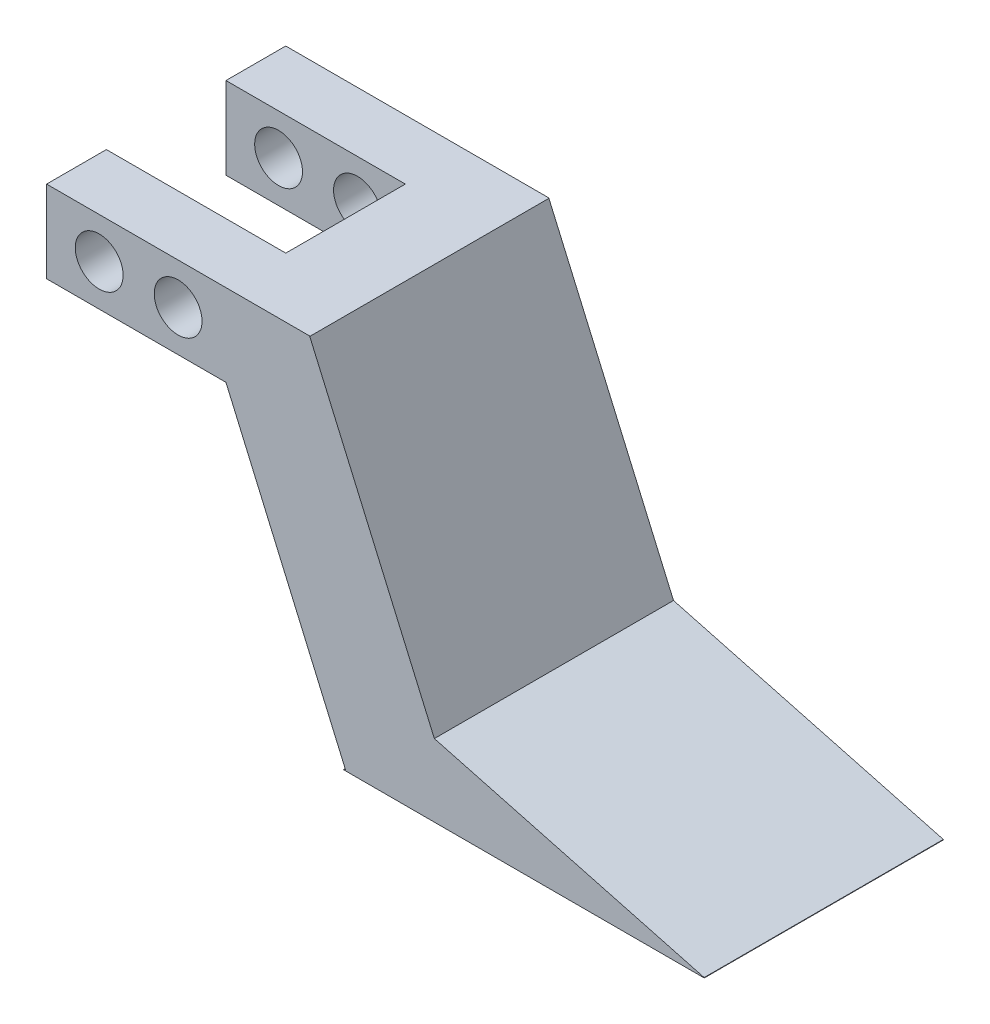
from build123d import *

# Parameters (mm, degrees)
SKETCH2_W               = 15
SKETCH2_H               = 6.86
BOSS_EXTRUDE1_DEPTH     = 20
SKETCH4_W               = 40
SKETCH4_H               = 30
BOSS_EXTRUDE2_DEPTH     = 20
CUT_EXTRUDE_THIN1_DEPTH = 20
CUT_EXTRUDE_THIN2_DEPTH = 20
SKETCH10_W              = 15
SKETCH10_H              = 10
CUT_EXTRUDE4_DEPTH      = 20
CUT_EXTRUDE5_DEPTH      = 20


with BuildPart() as part:
    # Sketch2 → Boss-Extrude1 (new body)
    with BuildSketch(Plane.XY):
        with Locations((7.425496689, 3.579006623)):
            Rectangle(SKETCH2_W, SKETCH2_H)
    extrude(amount=BOSS_EXTRUDE1_DEPTH)

    # Sketch4 → Boss-Extrude2 (add)
    with BuildSketch(Plane.XY.offset(20)):
        with Locations((34.925496689, -7.990993377)):
            Rectangle(SKETCH4_W, SKETCH4_H)
    extrude(amount=-BOSS_EXTRUDE2_DEPTH)

    # Sketch6 → Cut-Extrude-Thin1 (cut)
    with BuildSketch(Plane.XY.offset(20)):
        Polygon((14.925491376, 0.149003146), (24.925496689, -22.915069368), (15.750749541, -26.893010391), (5.750744229, -3.828937877), align=None)
    extrude(amount=-CUT_EXTRUDE_THIN1_DEPTH, mode=Mode.SUBTRACT)

    # Sketch7 → Cut-Extrude-Thin2 (cut)
    with BuildSketch(Plane.XY.offset(20)):
        Polygon((21.92715857, 6.994080588), (32.354035132, -16.936455783), (54.974089749, -22.976067343), (57.553745552, -13.314526268), (39.594610752, -8.51939204), (31.094733139, 10.988523793), align=None)
        Polygon((22.041113505, 7.165012991), (54.974089749, 6.994080588), (54.917112281, -22.976067343), (64.917094209, -22.995078715), (64.993020621, 16.942213912), (22.09301592, 17.164878297), align=None)
    extrude(amount=-CUT_EXTRUDE_THIN2_DEPTH, mode=Mode.SUBTRACT)


with BuildPart() as body_2:
    # of the pieces the cut leaves, the one that is kept (cut_extrude_thin2_keep)
    add(part.part.solids().sort_by_distance((-0.074503311, 0.149006623, 0))[0])

    # Sketch10 → Cut-Extrude4 (cut)
    with BuildSketch(Plane(origin=(0, 7.009006623, 0), x_dir=(1, 0, 0), z_dir=(0, 1, 0))):
        with Locations((7.425496689, -10)):
            Rectangle(SKETCH10_W, SKETCH10_H)
    extrude(amount=-CUT_EXTRUDE4_DEPTH, mode=Mode.SUBTRACT)

    # Sketch11 → Cut-Extrude5 (cut)
    with BuildSketch(Plane.XY.offset(20)):
        with BuildLine():
            ThreePointArc((6.325496689, 3.60059408), (4.314702178, 5.60056495), (2.32561321, 3.579005373))
            Line((2.32561321, 3.579005373), (6.325380145, 3.579003291))
            ThreePointArc((6.325380145, 3.579003291), (6.325467553, 3.589798528), (6.325496689, 3.60059408))
        make_face()
        with BuildLine():
            Line((6.325380145, 3.579003291), (2.32561321, 3.579005373))
            ThreePointArc((2.32561321, 3.579005373), (4.325495648, 1.60059408), (6.325380145, 3.579003291))
        make_face()
        with BuildLine():
            ThreePointArc((12.92549092, 3.578999855), (10.92549773, 5.574196049), (8.925502463, 3.579001937))
            Line((8.925502463, 3.579001937), (12.92549092, 3.578999855))
        make_face()
        with BuildLine():
            Line((12.92549092, 3.578999855), (8.925502463, 3.579001937))
            ThreePointArc((8.925502463, 3.579001937), (10.923093743, 1.574197492), (12.925496689, 3.574196049))
            ThreePointArc((12.925496689, 3.574196049), (12.925495246, 3.576597954), (12.92549092, 3.578999855))
        make_face()
    extrude(amount=-CUT_EXTRUDE5_DEPTH, mode=Mode.SUBTRACT)


solid = body_2.part
